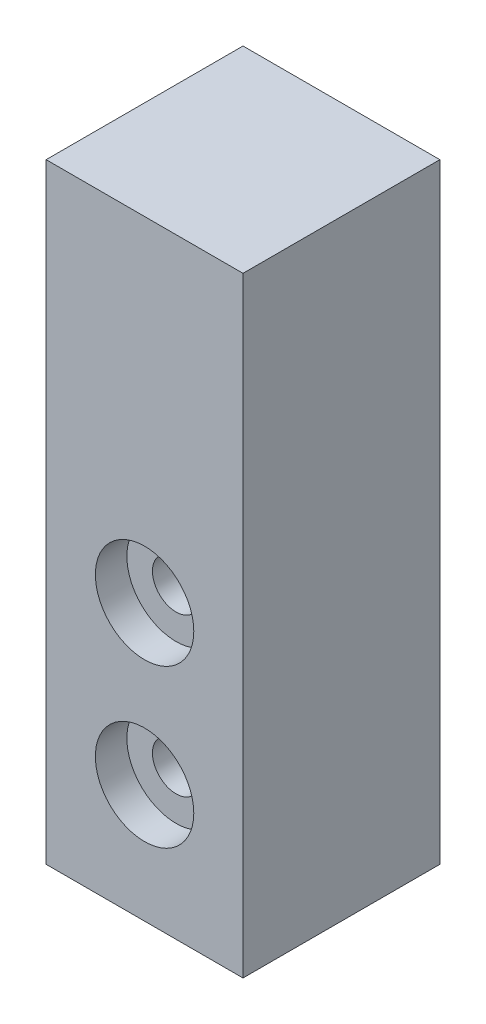
from build123d import *

# Parameters (mm, degrees)
SKETCH1_W                                = 10
SKETCH1_H                                = 31
BOSS_EXTRUDE1_DEPTH                      = 10
CBORE_FOR_M2_PAN_HEAD_SCREW1_D           = 2.4
CBORE_FOR_M2_PAN_HEAD_SCREW1_DEPTH       = 10
CBORE_FOR_M2_PAN_HEAD_SCREW1_CBORE_D     = 5
CBORE_FOR_M2_PAN_HEAD_SCREW1_CBORE_DEPTH = 1.6
CBORE_FOR_M2_PAN_HEAD_SCREW1_TIP         = 0.721032743


with BuildPart() as part:
    # Sketch1 → Boss-Extrude1 (new body)
    with BuildSketch(Plane.XY):
        with Locations((5, 15.5)):
            Rectangle(SKETCH1_W, SKETCH1_H)
    extrude(amount=BOSS_EXTRUDE1_DEPTH)

    # CBORE for M2 Pan Head Screw1
    with Locations(Plane(origin=(5, 14, 10), x_dir=(1, 0, 0), z_dir=(0, 0, 1))):
        with Locations((0, 0), (0, -8)):
            CounterBoreHole(CBORE_FOR_M2_PAN_HEAD_SCREW1_D / 2, CBORE_FOR_M2_PAN_HEAD_SCREW1_CBORE_D / 2, CBORE_FOR_M2_PAN_HEAD_SCREW1_CBORE_DEPTH, depth=CBORE_FOR_M2_PAN_HEAD_SCREW1_DEPTH)
            with Locations((0, 0, -(CBORE_FOR_M2_PAN_HEAD_SCREW1_DEPTH + CBORE_FOR_M2_PAN_HEAD_SCREW1_TIP / 2))):  # 118° drill point
                Cone(0, CBORE_FOR_M2_PAN_HEAD_SCREW1_D / 2, CBORE_FOR_M2_PAN_HEAD_SCREW1_TIP, mode=Mode.SUBTRACT)


solid = part.part
